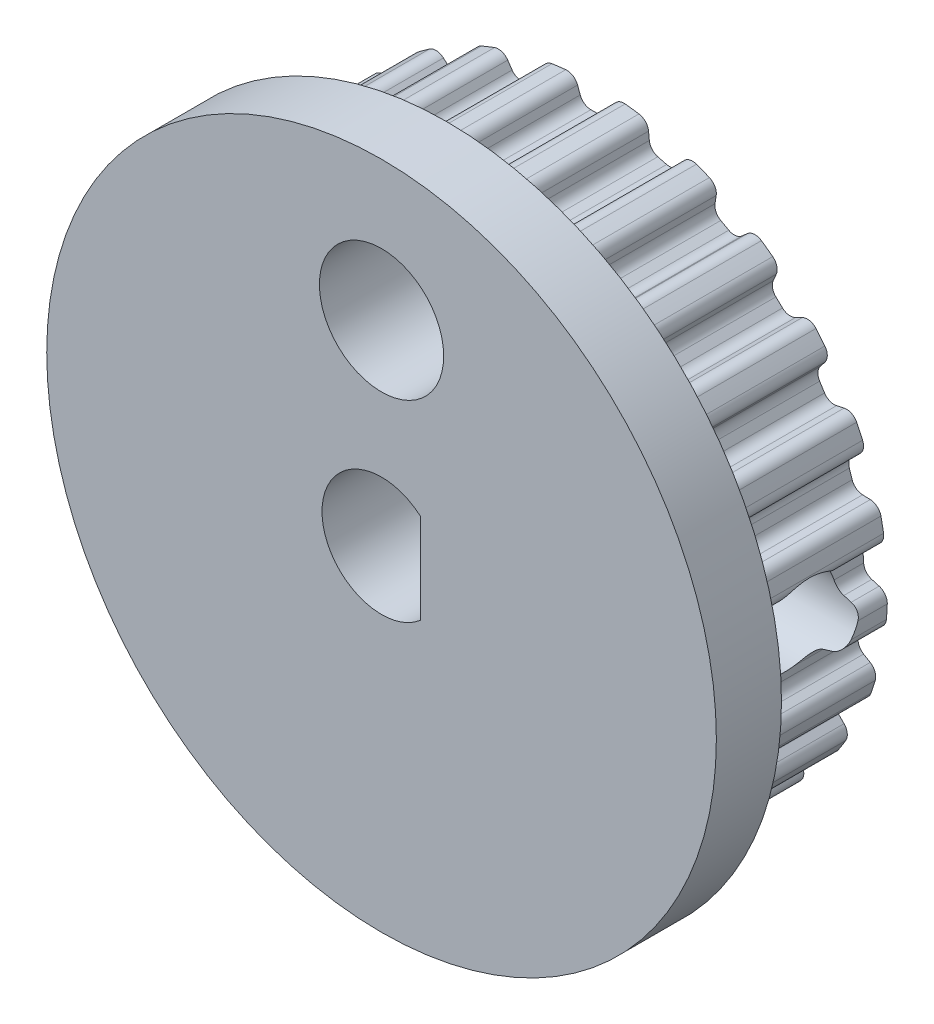
from build123d import *

# Parameters (mm, degrees)
BOSS_EXTRUDE1_DEPTH     = 4.000000001
SKETCH2_R               = 9
BOSS_EXTRUDE2_DEPTH     = 1.75
SKETCH4_W               = 4.5
SKETCH4_H               = 4.5
BOSS_EXTRUDE3_DEPTH     = 1.75
CUT_EXTRUDE2_DEPTH      = 8.500000001
SKETCH5_R               = 1.67
CUT_EXTRUDE3_DEPTH      = 8.500000001
CUT_EXTRUDE4_DEPTH      = 1
CUT_EXTRUDE4_DEPTH_BACK = 10


with BuildPart() as part:
    # Sketch1 → Boss-Extrude1 (new body)
    with BuildSketch(Plane(origin=(0, 0, -5.299999992), x_dir=(-1, 0, 0), z_dir=(0, 0, -1))):
        with BuildLine():
            Line((-2.770498963, -6.663011251), (-2.541538281, -6.753663208))
            ThreePointArc((-2.541538281, -6.753663208), (-2.399281022, -6.869272551), (-2.349061487, -7.04556959))
            Line((-2.349061487, -7.04556959), (-2.354850369, -7.252814955))
            ThreePointArc((-2.354850369, -7.252814955), (-2.295763451, -7.44184279), (-2.13298896, -7.55465791))
            ThreePointArc((-2.13298896, -7.55465791), (-1.9522156, -7.60337769), (-1.770331764, -7.647772452))
            ThreePointArc((-1.770331764, -7.647772452), (-1.573342284, -7.627329016), (-1.430499165, -7.490147994))
            Line((-1.430499165, -7.490147994), (-1.335730789, -7.305748684))
            ThreePointArc((-1.335730789, -7.305748684), (-1.206791332, -7.175451857), (-1.026435123, -7.142675578))
            Line((-1.026435123, -7.142675578), (-0.782123427, -7.173539321))
            ThreePointArc((-0.782123427, -7.173539321), (-0.615584572, -7.250138629), (-0.523099481, -7.408407869))
            Line((-0.523099481, -7.408407869), (-0.477166643, -7.610581923))
            ThreePointArc((-0.477166643, -7.610581923), (-0.372926733, -7.778976773), (-0.187210126, -7.847767225))
            ThreePointArc((-0.187210126, -7.847767225), (1.8e-08, -7.849999876), (0.187210163, -7.847767225))
            ThreePointArc((0.187210163, -7.847767225), (0.372926769, -7.778976773), (0.477166678, -7.610581924))
            Line((0.477166678, -7.610581924), (0.523099513, -7.408407881))
            ThreePointArc((0.523099513, -7.408407881), (0.615584602, -7.250138644), (0.782123452, -7.173539334))
            Line((0.782123452, -7.173539334), (1.026435157, -7.142675586))
            ThreePointArc((1.026435157, -7.142675586), (1.206791369, -7.175451863), (1.33573083, -7.305748691))
            Line((1.33573083, -7.305748691), (1.430499202, -7.490147994))
            ThreePointArc((1.430499202, -7.490147994), (1.573342321, -7.627329016), (1.770331801, -7.647772452))
            ThreePointArc((1.770331801, -7.647772452), (1.952215637, -7.60337769), (2.132988997, -7.55465791))
            ThreePointArc((2.132988997, -7.55465791), (2.295763494, -7.441842782), (2.354850406, -7.252814935))
            Line((2.354850406, -7.252814935), (2.349061514, -7.045569606))
            ThreePointArc((2.349061514, -7.045569606), (2.399281043, -6.869272556), (2.541538305, -6.753663204))
            Line((2.541538305, -6.753663204), (2.770498989, -6.663011244))
            ThreePointArc((2.770498989, -6.663011244), (2.953340111, -6.64990502), (3.11063221, -6.744042389))
            Line((3.11063221, -6.744042389), (3.248281539, -6.899080544))
            ThreePointArc((3.248281539, -6.899080544), (3.42075251, -6.996428125), (3.616637274, -6.967240001))
            ThreePointArc((3.616637274, -6.967240001), (3.781766365, -6.879007311), (3.94474428, -6.786861647))
            ThreePointArc((3.94474428, -6.786861647), (4.074348937, -6.637110438), (4.084570207, -6.439326927))
            Line((4.084570207, -6.439326927), (4.027423359, -6.240032231))
            ThreePointArc((4.027423359, -6.240032231), (4.032221853, -6.056784784), (4.141258967, -5.909429568))
            Line((4.141258967, -5.909429568), (4.340482222, -5.76468539))
            ThreePointArc((4.340482222, -5.76468539), (4.514319692, -5.706520185), (4.690081199, -5.758583127))
            Line((4.690081199, -5.758583127), (4.861962355, -5.874518455))
            ThreePointArc((4.861962355, -5.874518455), (5.053224205, -5.925915922), (5.235696117, -5.848930236))
            ThreePointArc((5.235696117, -5.848930236), (5.373694804, -5.722403597), (5.50863678, -5.592621893))
            ThreePointArc((5.50863678, -5.592621893), (5.596928058, -5.415344021), (5.557641445, -5.221232311))
            Line((5.557641445, -5.221232311), (5.452727407, -5.042410696))
            ThreePointArc((5.452727407, -5.042410696), (5.411803358, -4.863726966), (5.480769122, -4.693884755))
            Line((5.480769122, -4.693884755), (5.637737001, -4.504143178))
            ThreePointArc((5.637737001, -4.504143178), (5.791647936, -4.404573728), (5.974835084, -4.411290898))
            Line((5.974835084, -4.411290898), (6.170148257, -4.480838795))
            ThreePointArc((6.170148257, -4.480838795), (6.368183279, -4.483056618), (6.525776925, -4.363110665))
            ThreePointArc((6.525776925, -4.363110665), (6.627974228, -4.206240225), (6.726401351, -4.046977156))
            ThreePointArc((6.726401351, -4.046977156), (6.767831585, -3.853311658), (6.681505632, -3.675068511))
            Line((6.681505632, -3.675068511), (6.535416505, -3.527955909))
            ThreePointArc((6.535416505, -3.527955909), (6.451341341, -3.365063263), (6.475902375, -3.183405886))
            Line((6.475902375, -3.183405886), (6.580751989, -2.960589078))
            ThreePointArc((6.580751989, -2.960589078), (6.705065617, -2.825871679), (6.884168106, -2.78682102))
            Line((6.884168106, -2.78682102), (7.090641024, -2.805611531))
            ThreePointArc((7.090641024, -2.805611531), (7.283005966, -2.758510368), (7.405819176, -2.603140787))
            ThreePointArc((7.405819176, -2.603140787), (7.46579367, -2.425783284), (7.52152141, -2.247045927))
            ThreePointArc((7.52152141, -2.247045927), (7.513487384, -2.049161499), (7.385546242, -1.897986579))
            Line((7.385546242, -1.897986579), (7.207461372, -1.791826697))
            ThreePointArc((7.207461372, -1.791826697), (7.085517816, -1.654960251), (7.06413088, -1.472901871))
            Line((7.06413088, -1.472901871), (7.110274201, -1.231010202))
            ThreePointArc((7.110274201, -1.231010202), (7.197179435, -1.069609688), (7.360943563, -0.987244916))
            Line((7.360943563, -0.987244916), (7.565602753, -0.95409736))
            ThreePointArc((7.565602753, -0.95409736), (7.740210608, -0.86063675), (7.820526569, -0.679605993))
            ThreePointArc((7.820526569, -0.679605993), (7.834509837, -0.492905448), (7.844036614, -0.305924525))
            ThreePointArc((7.844036614, -0.305924525), (7.78704314, -0.116254991), (7.625525841, -0.001647178))
            Line((7.625525841, -0.001647178), (7.426634918, 0.056889606))
            ThreePointArc((7.426634918, 0.056889606), (7.274485151, 0.15913001), (7.208494045, 0.330149967))
            Line((7.208494045, 0.330149967), (7.193031666, 0.575917525))
            ThreePointArc((7.193031666, 0.575917525), (7.237067931, 0.753859804), (7.375203825, 0.874363422))
            Line((7.375203825, 0.874363422), (7.565189822, 0.957366261))
            ThreePointArc((7.565189822, 0.957366261), (7.711069345, 1.091313843), (7.743841513, 1.286630957))
            ThreePointArc((7.743841513, 1.286630957), (7.710954935, 1.470943449), (7.673682148, 1.654419227))
            ThreePointArc((7.673682148, 1.654419227), (7.571310327, 1.82395625), (7.386365577, 1.894795725))
            Line((7.386365577, 1.894795725), (7.179165715, 1.902031296))
            ThreePointArc((7.179165715, 1.902031296), (7.006369859, 1.963221511), (6.899921047, 2.112457233))
            Line((6.899921047, 2.112457233), (6.823824527, 2.346658216))
            ThreePointArc((6.823824527, 2.346658216), (6.822224861, 2.529961496), (6.926052937, 2.681032281))
            Line((6.926052937, 2.681032281), (7.089428199, 2.808675019))
            ThreePointArc((7.089428199, 2.808675019), (7.197413244, 2.974693155), (7.180582424, 3.172024133))
            ThreePointArc((7.180582424, 3.172024133), (7.10289238, 3.342367562), (7.02116201, 3.510809758))
            ThreePointArc((7.02116201, 3.510809758), (6.879844249, 3.649561624), (6.683092823, 3.67218166))
            Line((6.683092823, 3.67218166), (6.480603082, 3.627661399))
            ThreePointArc((6.480603082, 3.627661399), (6.298018541, 3.643956633), (6.157800604, 3.762031099))
            Line((6.157800604, 3.762031099), (6.025851382, 3.969949803))
            ThreePointArc((6.025851382, 3.969949803), (5.978716304, 4.147096461), (6.041712663, 4.319242076))
            Line((6.041712663, 4.319242076), (6.168211718, 4.483504424))
            ThreePointArc((6.168211718, 4.483504424), (6.231517191, 4.671161588), (6.166140924, 4.858107403))
            ThreePointArc((6.166140924, 4.858107403), (6.048528974, 5.003778443), (5.927476451, 5.146603192))
            ThreePointArc((5.927476451, 5.146603192), (5.756092274, 5.245851614), (5.559896791, 5.218830927))
            Line((5.559896791, 5.218830927), (5.374840317, 5.125352196))
            ThreePointArc((5.374840317, 5.125352196), (5.193939557, 5.095728573), (5.028762915, 5.175222731))
            Line((5.028762915, 5.175222731), (4.849251859, 5.343794843))
            ThreePointArc((4.849251859, 5.343794843), (4.759543042, 5.50365408), (4.777749369, 5.686057966))
            Line((4.777749369, 5.686057966), (4.859423838, 5.876618788))
            ThreePointArc((4.859423838, 5.876618788), (4.874072, 6.074123776), (4.764258119, 6.238937914))
            ThreePointArc((4.764258119, 6.238937914), (4.614114251, 6.350783528), (4.461345743, 6.459016637))
            ThreePointArc((4.461345743, 6.459016637), (4.270663826, 6.512525475), (4.087351951, 6.437561846))
            Line((4.087351951, 6.437561846), (3.931356637, 6.300998273))
            ThreePointArc((3.931356637, 6.300998273), (3.763506296, 6.227317127), (3.583749576, 6.263236065))
            Line((3.583749576, 6.263236065), (3.367956, 6.381869588))
            ThreePointArc((3.367956, 6.381869588), (3.241310171, 6.514396877), (3.213582509, 6.69559794))
            Line((3.213582509, 6.69559794), (3.245300476, 6.900483573))
            ThreePointArc((3.245300476, 6.900483573), (3.210370947, 7.095426422), (3.063019466, 7.227753016))
            ThreePointArc((3.063019466, 7.227753016), (2.889777761, 7.298745536), (2.714892269, 7.365586324))
            ThreePointArc((2.714892269, 7.365586324), (2.516893872, 7.369993419), (2.357983776, 7.251797104))
            Line((2.357983776, 7.251797104), (2.240851316, 7.080729469))
            ThreePointArc((2.240851316, 7.080729469), (2.096598059, 6.967620471), (1.913556053, 6.957707268))
            Line((1.913556053, 6.957707268), (1.675039076, 7.018948014))
            ThreePointArc((1.675039076, 7.018948014), (1.51941385, 7.115816183), (1.447494432, 7.284428907))
            Line((1.447494432, 7.284428907), (1.427262951, 7.490765576))
            ThreePointArc((1.427262951, 7.490765576), (1.344950483, 7.670897333), (1.169320022, 7.762421829))
            ThreePointArc((1.169320022, 7.762421829), (0.983865903, 7.788100529), (0.797852133, 7.809349137))
            ThreePointArc((0.797852133, 7.809349137), (0.604978216, 7.764377573), (0.480454802, 7.610375273))
            Line((0.480454802, 7.610375273), (0.409545077, 7.415552396))
            ThreePointArc((0.409545077, 7.415552396), (0.297952865, 7.270122591), (0.123126767, 7.215000134))
            Line((0.123126767, 7.215000134), (-0.12312673, 7.215000134))
            ThreePointArc((-0.12312673, 7.215000134), (-0.297952827, 7.270122591), (-0.409545038, 7.415552395))
            Line((-0.409545038, 7.415552395), (-0.480454763, 7.610375271))
            ThreePointArc((-0.480454763, 7.610375271), (-0.604978178, 7.764377573), (-0.797852096, 7.809349137))
            ThreePointArc((-0.797852096, 7.809349137), (-0.983865866, 7.788100529), (-1.169319985, 7.762421829))
            ThreePointArc((-1.169319985, 7.762421829), (-1.344950446, 7.670897333), (-1.427262914, 7.490765576))
            Line((-1.427262914, 7.490765576), (-1.447494396, 7.284428898))
            ThreePointArc((-1.447494396, 7.284428898), (-1.519413814, 7.115816175), (-1.67503904, 7.018948005))
            Line((-1.67503904, 7.018948005), (-1.913556012, 6.957707261))
            ThreePointArc((-1.913556012, 6.957707261), (-2.096598018, 6.967620464), (-2.240851274, 7.080729462))
            Line((-2.240851274, 7.080729462), (-2.357983739, 7.251797104))
            ThreePointArc((-2.357983739, 7.251797104), (-2.516893836, 7.369993419), (-2.714892233, 7.365586324))
            ThreePointArc((-2.714892233, 7.365586324), (-2.889777725, 7.298745536), (-3.063019429, 7.227753016))
            ThreePointArc((-3.063019429, 7.227753016), (-3.210370911, 7.095426422), (-3.24530044, 6.900483573))
            Line((-3.24530044, 6.900483573), (-3.21358247, 6.695597928))
            ThreePointArc((-3.21358247, 6.695597928), (-3.241310132, 6.514396865), (-3.367955962, 6.381869576))
            Line((-3.367955962, 6.381869576), (-3.58374953, 6.263236057))
            ThreePointArc((-3.58374953, 6.263236057), (-3.76350625, 6.227317119), (-3.931356591, 6.300998266))
            Line((-3.931356591, 6.300998266), (-4.087351915, 6.437561846))
            ThreePointArc((-4.087351915, 6.437561846), (-4.27066379, 6.512525475), (-4.461345707, 6.459016637))
            ThreePointArc((-4.461345707, 6.459016637), (-4.614114214, 6.350783528), (-4.764258082, 6.238937914))
            ThreePointArc((-4.764258082, 6.238937914), (-4.874071964, 6.074123776), (-4.859423801, 5.876618788))
            Line((-4.859423801, 5.876618788), (-4.77774934, 5.686057982))
            ThreePointArc((-4.77774934, 5.686057982), (-4.759543013, 5.503654097), (-4.849251829, 5.343794859))
            Line((-4.849251829, 5.343794859), (-5.028762894, 5.17522274))
            ThreePointArc((-5.028762894, 5.17522274), (-5.193939536, 5.095728582), (-5.374840296, 5.125352204))
            Line((-5.374840296, 5.125352204), (-5.559896754, 5.218830927))
            ThreePointArc((-5.559896754, 5.218830927), (-5.756092237, 5.245851614), (-5.927476414, 5.146603192))
            ThreePointArc((-5.927476414, 5.146603192), (-6.048528938, 5.003778443), (-6.166140887, 4.858107403))
            ThreePointArc((-6.166140887, 4.858107403), (-6.231517154, 4.671161588), (-6.168211682, 4.483504424))
            Line((-6.168211682, 4.483504424), (-6.04171263, 4.31924208))
            ThreePointArc((-6.04171263, 4.31924208), (-5.978716271, 4.147096465), (-6.025851349, 3.969949807))
            Line((-6.025851349, 3.969949807), (-6.157800573, 3.7620311))
            ThreePointArc((-6.157800573, 3.7620311), (-6.29801851, 3.643956634), (-6.480603051, 3.6276614))
            Line((-6.480603051, 3.6276614), (-6.683092787, 3.67218166))
            ThreePointArc((-6.683092787, 3.67218166), (-6.879844213, 3.649561624), (-7.021161973, 3.510809758))
            ThreePointArc((-7.021161973, 3.510809758), (-7.102892344, 3.342367562), (-7.180582387, 3.172024133))
            ThreePointArc((-7.180582387, 3.172024133), (-7.197413207, 2.974693155), (-7.089428162, 2.808675019))
            Line((-7.089428162, 2.808675019), (-6.926052897, 2.681032278))
            ThreePointArc((-6.926052897, 2.681032278), (-6.822224821, 2.529961494), (-6.823824488, 2.346658214))
            Line((-6.823824488, 2.346658214), (-6.899921006, 2.112457233))
            ThreePointArc((-6.899921006, 2.112457233), (-7.006369819, 1.963221511), (-7.179165675, 1.902031296))
            Line((-7.179165675, 1.902031296), (-7.386365541, 1.894795725))
            ThreePointArc((-7.386365541, 1.894795725), (-7.571310291, 1.82395625), (-7.673682111, 1.654419227))
            ThreePointArc((-7.673682111, 1.654419227), (-7.710954911, 1.470943384), (-7.743841498, 1.286630826))
            ThreePointArc((-7.743841498, 1.286630826), (-7.711069328, 1.091313715), (-7.565189806, 0.957366136))
            Line((-7.565189806, 0.957366136), (-7.375203809, 0.874363296))
            ThreePointArc((-7.375203809, 0.874363296), (-7.237067915, 0.753859678), (-7.19303165, 0.5759174))
            Line((-7.19303165, 0.5759174), (-7.20849403, 0.330149843))
            ThreePointArc((-7.20849403, 0.330149843), (-7.274485135, 0.159129886), (-7.426634903, 0.056889483))
            Line((-7.426634903, 0.056889483), (-7.6255258, -0.001647294))
            ThreePointArc((-7.6255258, -0.001647294), (-7.7870431, -0.116255109), (-7.844036572, -0.305924646))
            ThreePointArc((-7.844036572, -0.305924646), (-7.834509796, -0.492905509), (-7.820526532, -0.679605993))
            ThreePointArc((-7.820526532, -0.679605993), (-7.740210572, -0.86063675), (-7.565602716, -0.95409736))
            Line((-7.565602716, -0.95409736), (-7.360943526, -0.987244916))
            ThreePointArc((-7.360943526, -0.987244916), (-7.197179397, -1.069609688), (-7.110274163, -1.231010202))
            Line((-7.110274163, -1.231010202), (-7.064130842, -1.47290187))
            ThreePointArc((-7.064130842, -1.47290187), (-7.085517778, -1.654960251), (-7.207461334, -1.791826697))
            Line((-7.207461334, -1.791826697), (-7.385546205, -1.897986579))
            ThreePointArc((-7.385546205, -1.897986579), (-7.513487347, -2.049161499), (-7.521521373, -2.247045927))
            ThreePointArc((-7.521521373, -2.247045927), (-7.465793634, -2.425783284), (-7.405819139, -2.603140787))
            ThreePointArc((-7.405819139, -2.603140787), (-7.28300593, -2.758510368), (-7.090640987, -2.805611531))
            Line((-7.090640987, -2.805611531), (-6.884168079, -2.786821021))
            ThreePointArc((-6.884168079, -2.786821021), (-6.705065589, -2.82587168), (-6.580751962, -2.960589079))
            Line((-6.580751962, -2.960589079), (-6.475902344, -3.183405892))
            ThreePointArc((-6.475902344, -3.183405892), (-6.451341311, -3.36506327), (-6.535416475, -3.527955915))
            Line((-6.535416475, -3.527955915), (-6.681505595, -3.675068511))
            ThreePointArc((-6.681505595, -3.675068511), (-6.767831549, -3.853311658), (-6.726401314, -4.046977156))
            ThreePointArc((-6.726401314, -4.046977156), (-6.627974191, -4.206240225), (-6.525776888, -4.363110665))
            ThreePointArc((-6.525776888, -4.363110665), (-6.368183242, -4.483056618), (-6.17014822, -4.480838795))
            Line((-6.17014822, -4.480838795), (-5.974835047, -4.411290898))
            ThreePointArc((-5.974835047, -4.411290898), (-5.791647899, -4.404573728), (-5.637736963, -4.504143178))
            Line((-5.637736963, -4.504143178), (-5.480769085, -4.693884754))
            ThreePointArc((-5.480769085, -4.693884754), (-5.411803321, -4.863726965), (-5.45272737, -5.042410695))
            Line((-5.45272737, -5.042410695), (-5.557641409, -5.221232311))
            ThreePointArc((-5.557641409, -5.221232311), (-5.596928022, -5.415344021), (-5.508636743, -5.592621893))
            ThreePointArc((-5.508636743, -5.592621893), (-5.373694767, -5.722403597), (-5.235696081, -5.848930236))
            ThreePointArc((-5.235696081, -5.848930236), (-5.053224168, -5.925915922), (-4.861962318, -5.874518455))
            Line((-4.861962318, -5.874518455), (-4.690081172, -5.758583134))
            ThreePointArc((-4.690081172, -5.758583134), (-4.514319665, -5.706520192), (-4.340482195, -5.764685397))
            Line((-4.340482195, -5.764685397), (-4.141258934, -5.909429579))
            ThreePointArc((-4.141258934, -5.909429579), (-4.032221819, -6.056784796), (-4.027423326, -6.240032243))
            Line((-4.027423326, -6.240032243), (-4.08457017, -6.439326927))
            ThreePointArc((-4.08457017, -6.439326927), (-4.0743489, -6.637110438), (-3.944744243, -6.786861647))
            ThreePointArc((-3.944744243, -6.786861647), (-3.781766328, -6.879007311), (-3.616637238, -6.967240001))
            ThreePointArc((-3.616637238, -6.967240001), (-3.420752473, -6.996428125), (-3.248281502, -6.899080544))
            Line((-3.248281502, -6.899080544), (-3.110632181, -6.744042398))
            ThreePointArc((-3.110632181, -6.744042398), (-2.953340083, -6.649905029), (-2.770498963, -6.663011251))
        make_face()
    extrude(amount=-BOSS_EXTRUDE1_DEPTH)

    # Sketch2 → Boss-Extrude2 (add)
    with BuildSketch(Plane.XY.offset(-1.299999991)):
        Circle(SKETCH2_R)
    extrude(amount=BOSS_EXTRUDE2_DEPTH)

    # Sketch4 → Boss-Extrude3 (add)
    with BuildSketch(Plane(origin=(0, 0, -5.299999992), x_dir=(-1, 0, 0), z_dir=(0, 0, -1))):
        Rectangle(SKETCH4_W, SKETCH4_H)
    extrude(amount=BOSS_EXTRUDE3_DEPTH)

    # Sketch3 → Cut-Extrude2 (cut, through all)
    with BuildSketch(Plane.XY.offset(0.450000009)):
        with BuildLine():
            Line((1.041610738, 1.214515158), (1.041610738, -1.214515158))
            ThreePointArc((1.041610738, -1.214515158), (-1.6, 0), (1.041610738, 1.214515158))
        make_face()
    extrude(amount=-CUT_EXTRUDE2_DEPTH, mode=Mode.SUBTRACT)

    # Sketch5 → Cut-Extrude3 (cut, through all)
    with BuildSketch(Plane.XY.offset(0.450000009)):
        with Locations((0, 5.25)):
            Circle(SKETCH5_R)
    extrude(amount=-CUT_EXTRUDE3_DEPTH, mode=Mode.SUBTRACT)

    # Sketch7 → Cut-Extrude4 (cut, two sides)
    with BuildSketch(Plane.ZY.offset(-1.041610738)) as cut_extrude4_sk:
        with BuildLine():
            ThreePointArc((-3.595724407, 1.214515158), (-4.282892539, 0.772283782), (-4.549999991, 0))
            Line((-4.549999991, 0), (-2.049999991, 0))
            ThreePointArc((-2.049999991, 0), (-2.317107444, 0.772283782), (-3.004275576, 1.214515158))
            Line((-3.004275576, 1.214515158), (-3.595724407, 1.214515158))
        make_face()
        with BuildLine():
            Line((-2.049999991, 0), (-4.549999991, 0))
            ThreePointArc((-4.549999991, 0), (-4.282892539, -0.772283782), (-3.595724407, -1.214515158))
            Line((-3.595724407, -1.214515158), (-3.004275576, -1.214515158))
            ThreePointArc((-3.004275576, -1.214515158), (-2.317107444, -0.772283782), (-2.049999991, 0))
        make_face()
        with BuildLine():
            ThreePointArc((-3.004275576, 1.214515158), (-3.299999991, 1.25), (-3.595724407, 1.214515158))
            Line((-3.595724407, 1.214515158), (-3.004275576, 1.214515158))
        make_face()
        with BuildLine():
            Line((-3.004275576, -1.214515158), (-3.595724407, -1.214515158))
            ThreePointArc((-3.595724407, -1.214515158), (-3.299999991, -1.25), (-3.004275576, -1.214515158))
        make_face()
    extrude(amount=CUT_EXTRUDE4_DEPTH, mode=Mode.SUBTRACT)
    extrude(cut_extrude4_sk.sketch, amount=-CUT_EXTRUDE4_DEPTH_BACK, mode=Mode.SUBTRACT)


solid = part.part
